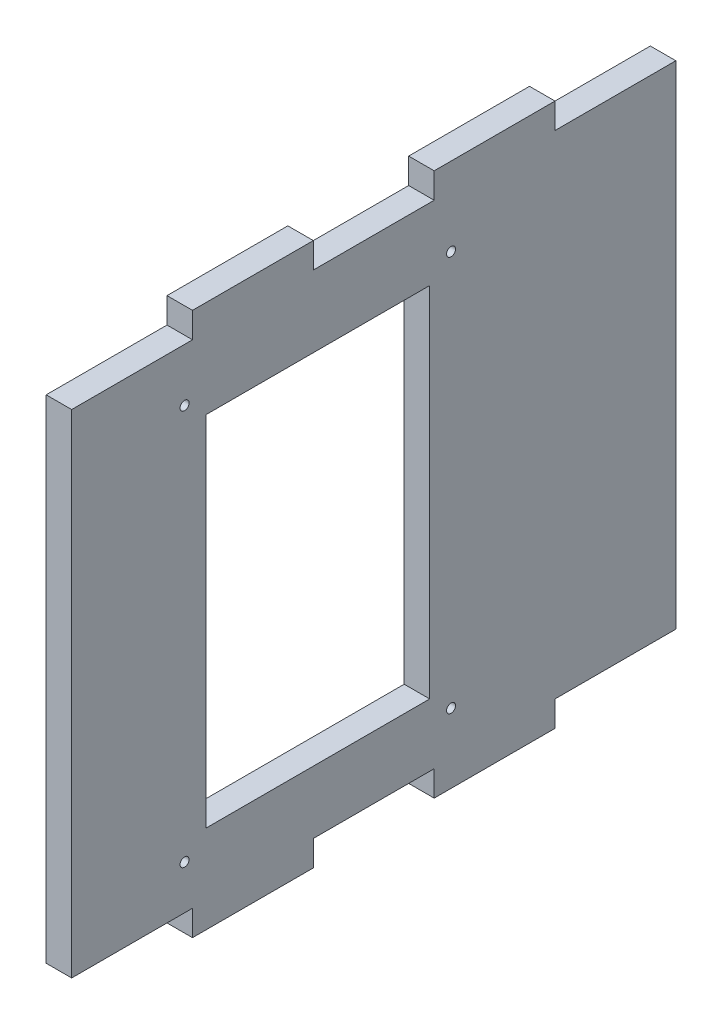
from build123d import *

# Parameters (mm, degrees)
SKETCH1_W           = 135
SKETCH1_H           = 122
BOSS_EXTRUDE1_DEPTH = 5.7
CUT_EXTRUDE1_DEPTH  = 6
HOLE_W              = 50
HOLE_H              = 80
CUT_EXTRUDE2_DEPTH  = 70
SCREW_LOCATIONS_R   = 1
CUT_EXTRUDE3_DEPTH  = 52


with BuildPart() as part:
    # Sketch1 → Boss-Extrude1 (new body)
    with BuildSketch(Plane(origin=(0, 0, 0), x_dir=(0, 0, -1), z_dir=(1, 0, 0))):
        with Locations((67.5, 61)):
            Rectangle(SKETCH1_W, SKETCH1_H)
    extrude(amount=BOSS_EXTRUDE1_DEPTH)

    # Sketch2 → Cut-Extrude1 (cut)
    with BuildSketch(Plane(origin=(0, 0, 0), x_dir=(0, 0, -1), z_dir=(1, 0, 0))):
        Polygon((0, 116), (27, 116), (27, 121.7), (54, 121.7), (54, 116), (81, 116), (81, 121.7), (108, 121.7), (108, 116), (135, 116), (135, 130), (0, 130), align=None)
        Polygon((0, -8), (0, 6), (27, 6), (27, 0.3), (54, 0.3), (54, 6), (81, 6), (81, 0.3), (108, 0.3), (108, 6), (135, 6), (135, -8), align=None)
    extrude(amount=CUT_EXTRUDE1_DEPTH, mode=Mode.SUBTRACT)

    # Hole → Cut-Extrude2 (cut)
    with BuildSketch(Plane(origin=(0, 0, 0), x_dir=(0, 0, -1), z_dir=(1, 0, 0))):
        with Locations((55, 60)):
            Rectangle(HOLE_W, HOLE_H)
    extrude(amount=CUT_EXTRUDE2_DEPTH, mode=Mode.SUBTRACT)

    # Screw Locations → Cut-Extrude3 (cut)
    with BuildSketch(Plane(origin=(0, 0, 0), x_dir=(0, 0, -1), z_dir=(1, 0, 0))):
        with Locations((25.23, 104.17)):
            Circle(SCREW_LOCATIONS_R)
        with Locations((84.77, 104.17)):
            Circle(SCREW_LOCATIONS_R)
        with Locations((25.23, 15.83)):
            Circle(SCREW_LOCATIONS_R)
        with Locations((84.77, 15.83)):
            Circle(SCREW_LOCATIONS_R)
    extrude(amount=CUT_EXTRUDE3_DEPTH, mode=Mode.SUBTRACT)


solid = part.part
